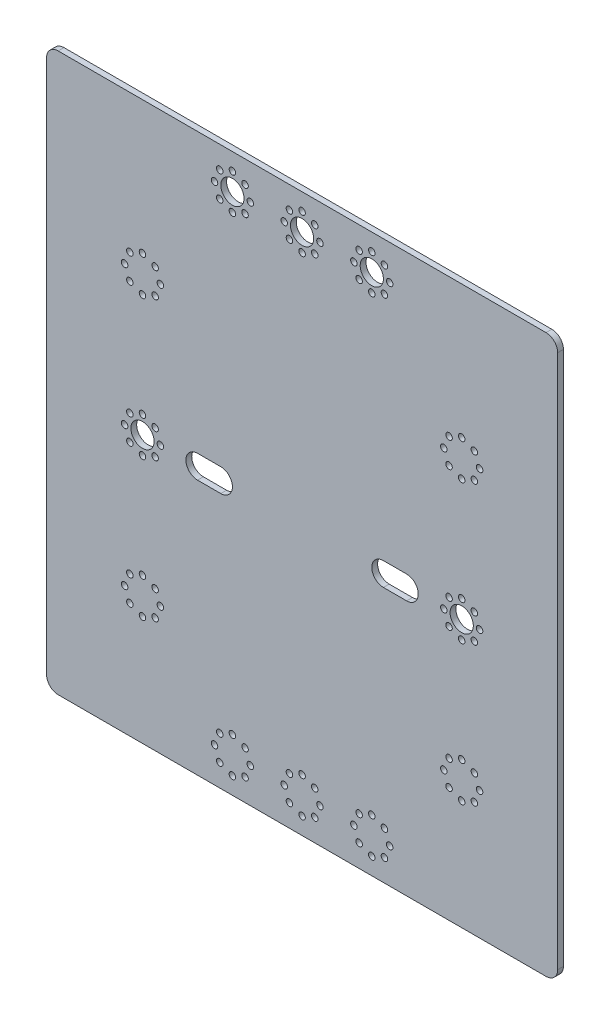
from build123d import *

# Parameters (mm, degrees)
SKETCH1_W                  = 279.4
SKETCH1_H                  = 304.8
BOSS_EXTRUDE1_DEPTH        = 3.175
SKETCH2_R                  = 6.35
CUT_EXTRUDE1_DEPTH         = 3.175
SKETCH3_R                  = 1.778
CUT_EXTRUDE2_DEPTH         = 3.175
CIRPATTERN1_COUNT          = 8
SKETCH4_R                  = 1.778
CUT_EXTRUDE3_DEPTH         = 3.175
CIRPATTERN2_COUNT          = 8
MIRROR1_COPY_1_SKETCH_R    = 1.778
MIRROR1_COPY_1_DEPTH       = 3.175
MIRROR1_COPY_2_SKETCH_R    = 1.778
MIRROR1_COPY_2_DEPTH       = 3.175
MIRROR1_COPY_3_SKETCH_R    = 1.778
MIRROR1_COPY_3_DEPTH       = 3.175
MIRROR1_COPY_4_SKETCH_R    = 1.778
MIRROR1_COPY_4_DEPTH       = 3.175
MIRROR1_COPY_5_SKETCH_R    = 1.778
MIRROR1_COPY_5_DEPTH       = 3.175
MIRROR1_COPY_6_SKETCH_R    = 1.778
MIRROR1_COPY_6_DEPTH       = 3.175
MIRROR1_COPY_7_SKETCH_R    = 1.778
MIRROR1_COPY_7_DEPTH       = 3.175
LPATTERN2_COUNT            = 4
LPATTERN2_PITCH            = 38.1
LPATTERN2_COPY_1_SKETCH_R  = 6.35
LPATTERN2_COPY_1_DEPTH     = 3.175
LPATTERN2_COPY_2_SKETCH_R  = 1.778
LPATTERN2_COPY_2_DEPTH     = 3.175
LPATTERN2_COPY_3_SKETCH_R  = 1.778
LPATTERN2_COPY_3_DEPTH     = 3.175
LPATTERN2_COPY_4_SKETCH_R  = 1.778
LPATTERN2_COPY_4_DEPTH     = 3.175
LPATTERN2_COPY_5_SKETCH_R  = 1.778
LPATTERN2_COPY_5_DEPTH     = 3.175
LPATTERN2_COPY_6_SKETCH_R  = 1.778
LPATTERN2_COPY_6_DEPTH     = 3.175
LPATTERN2_COPY_7_SKETCH_R  = 1.778
LPATTERN2_COPY_7_DEPTH     = 3.175
LPATTERN2_COPY_8_SKETCH_R  = 1.778
LPATTERN2_COPY_8_DEPTH     = 3.175
LPATTERN2_COPY_9_SKETCH_R  = 1.778
LPATTERN2_COPY_9_DEPTH     = 3.175
LPATTERN2_COPY_10_SKETCH_R = 1.778
LPATTERN2_COPY_10_DEPTH    = 3.175
LPATTERN2_COPY_11_SKETCH_R = 1.778
LPATTERN2_COPY_11_DEPTH    = 3.175
LPATTERN2_COPY_12_SKETCH_R = 1.778
LPATTERN2_COPY_12_DEPTH    = 3.175
LPATTERN2_COPY_13_SKETCH_R = 1.778
LPATTERN2_COPY_13_DEPTH    = 3.175
LPATTERN2_COPY_14_SKETCH_R = 1.778
LPATTERN2_COPY_14_DEPTH    = 3.175
LPATTERN2_COPY_15_SKETCH_R = 1.778
LPATTERN2_COPY_15_DEPTH    = 3.175
LPATTERN2_COPY_16_SKETCH_R = 1.778
LPATTERN2_COPY_16_DEPTH    = 3.175
LPATTERN3_COUNT            = 4
LPATTERN3_PITCH            = 38.1
LPATTERN3_COPY_1_SKETCH_R  = 1.778
LPATTERN3_COPY_1_DEPTH     = 3.175
LPATTERN3_COPY_2_SKETCH_R  = 1.778
LPATTERN3_COPY_2_DEPTH     = 3.175
LPATTERN3_COPY_3_SKETCH_R  = 1.778
LPATTERN3_COPY_3_DEPTH     = 3.175
LPATTERN3_COPY_4_SKETCH_R  = 1.778
LPATTERN3_COPY_4_DEPTH     = 3.175
LPATTERN3_COPY_5_SKETCH_R  = 1.778
LPATTERN3_COPY_5_DEPTH     = 3.175
LPATTERN3_COPY_6_SKETCH_R  = 1.778
LPATTERN3_COPY_6_DEPTH     = 3.175
LPATTERN3_COPY_7_SKETCH_R  = 1.778
LPATTERN3_COPY_7_DEPTH     = 3.175
SKETCH5_R                  = 6.35
BOSS_EXTRUDE4_DEPTH        = 3.175
MIRROR4_COPY_1_SKETCH_R    = 1.778
MIRROR4_COPY_1_DEPTH       = 3.175
MIRROR4_COPY_2_SKETCH_R    = 1.778
MIRROR4_COPY_2_DEPTH       = 3.175
MIRROR4_COPY_3_SKETCH_R    = 1.778
MIRROR4_COPY_3_DEPTH       = 3.175
MIRROR4_COPY_4_SKETCH_R    = 1.778
MIRROR4_COPY_4_DEPTH       = 3.175
MIRROR4_COPY_5_SKETCH_R    = 1.778
MIRROR4_COPY_5_DEPTH       = 3.175
MIRROR4_COPY_6_SKETCH_R    = 1.778
MIRROR4_COPY_6_DEPTH       = 3.175
MIRROR4_COPY_7_SKETCH_R    = 1.778
MIRROR4_COPY_7_DEPTH       = 3.175
MIRROR4_COPY_8_SKETCH_R    = 1.778
MIRROR4_COPY_8_DEPTH       = 3.175
MIRROR4_COPY_9_SKETCH_R    = 1.778
MIRROR4_COPY_9_DEPTH       = 3.175
SKETCH6_R                  = 6.35
CUT_EXTRUDE4_DEPTH         = 3.175
SKETCH7_R                  = 1.778
CUT_EXTRUDE5_DEPTH         = 3.175
CIRPATTERN3_COUNT          = 8
SKETCH8_R                  = 1.778
CUT_EXTRUDE6_DEPTH         = 3.175
CIRPATTERN4_COUNT          = 8
MIRROR5_COPY_1_SKETCH_R    = 1.778
MIRROR5_COPY_1_DEPTH       = 3.175
MIRROR5_COPY_2_SKETCH_R    = 1.778
MIRROR5_COPY_2_DEPTH       = 3.175
MIRROR5_COPY_3_SKETCH_R    = 1.778
MIRROR5_COPY_3_DEPTH       = 3.175
MIRROR5_COPY_4_SKETCH_R    = 1.778
MIRROR5_COPY_4_DEPTH       = 3.175
MIRROR5_COPY_5_SKETCH_R    = 1.778
MIRROR5_COPY_5_DEPTH       = 3.175
MIRROR5_COPY_6_SKETCH_R    = 1.778
MIRROR5_COPY_6_DEPTH       = 3.175
MIRROR5_COPY_7_SKETCH_R    = 1.778
MIRROR5_COPY_7_DEPTH       = 3.175
MIRROR5_COPY_8_SKETCH_R    = 1.778
MIRROR5_COPY_8_DEPTH       = 3.175
MIRROR5_COPY_9_SKETCH_R    = 1.778
MIRROR5_COPY_9_DEPTH       = 3.175
MIRROR5_COPY_10_SKETCH_R   = 1.778
MIRROR5_COPY_10_DEPTH      = 3.175
MIRROR5_COPY_11_SKETCH_R   = 1.778
MIRROR5_COPY_11_DEPTH      = 3.175
MIRROR5_COPY_12_SKETCH_R   = 1.778
MIRROR5_COPY_12_DEPTH      = 3.175
MIRROR5_COPY_13_SKETCH_R   = 1.778
MIRROR5_COPY_13_DEPTH      = 3.175
MIRROR5_COPY_14_SKETCH_R   = 1.778
MIRROR5_COPY_14_DEPTH      = 3.175
FILLET1_R                  = 6.35
CUT_EXTRUDE8_DEPTH         = 3.175
MIRROR8_COPY_1_SKETCH_R    = 1.778
MIRROR8_COPY_1_DEPTH       = 3.175
MIRROR8_COPY_2_SKETCH_R    = 1.778
MIRROR8_COPY_2_DEPTH       = 3.175
MIRROR8_COPY_3_SKETCH_R    = 1.778
MIRROR8_COPY_3_DEPTH       = 3.175
MIRROR8_COPY_4_SKETCH_R    = 1.778
MIRROR8_COPY_4_DEPTH       = 3.175
MIRROR8_COPY_5_SKETCH_R    = 1.778
MIRROR8_COPY_5_DEPTH       = 3.175
MIRROR8_COPY_6_SKETCH_R    = 1.778
MIRROR8_COPY_6_DEPTH       = 3.175
MIRROR8_COPY_7_SKETCH_R    = 1.778
MIRROR8_COPY_7_DEPTH       = 3.175


with BuildPart() as part:
    # Sketch1 → Boss-Extrude1 (new body)
    with BuildSketch(Plane.XY):
        with Locations((-139.7, -152.4)):
            Rectangle(SKETCH1_W, SKETCH1_H)
    extrude(amount=BOSS_EXTRUDE1_DEPTH)

    # Sketch2 → Cut-Extrude1 (cut)
    with BuildSketch(Plane.XY.offset(3.175)):
        with Locations((-139.7, -19.05)):
            Circle(SKETCH2_R)
        with Locations((-226.949, -158.75)):
            Circle(SKETCH2_R)
    cut_extrude1 = extrude(amount=-CUT_EXTRUDE1_DEPTH, mode=Mode.SUBTRACT)

    # Sketch3 → Cut-Extrude2 (cut)
    with BuildSketch(Plane.XY.offset(3.175)):
        with Locations((-139.7, -9.271)):
            Circle(SKETCH3_R)
    cut_extrude2 = extrude(amount=-CUT_EXTRUDE2_DEPTH, mode=Mode.SUBTRACT)

    # CirPattern1: Cut-Extrude2 ×8 about axis
    cirpattern1_axis = Axis((-139.7, -19.05, 0), (0, 0, 1))
    for i in range(1, CIRPATTERN1_COUNT):
        add(cut_extrude2.rotate(cirpattern1_axis, i * 360 / CIRPATTERN1_COUNT), mode=Mode.SUBTRACT)

    # Sketch4 → Cut-Extrude3 (cut)
    with BuildSketch(Plane.XY.offset(3.175)):
        with Locations((-226.949, -148.971)):
            Circle(SKETCH4_R)
    cut_extrude3 = extrude(amount=-CUT_EXTRUDE3_DEPTH, mode=Mode.SUBTRACT)

    # CirPattern2: Cut-Extrude3 ×8 about axis
    cirpattern2_axis = Axis((-226.949, -158.75, 0), (0, 0, 1))
    for i in range(1, CIRPATTERN2_COUNT):
        add(cut_extrude3.rotate(cirpattern2_axis, i * 360 / CIRPATTERN2_COUNT), mode=Mode.SUBTRACT)

    # Mirror1: Cut-Extrude1, Cut-Extrude3 across plane
    add(cut_extrude1.mirror(Plane.ZY.offset(139.7)), mode=Mode.SUBTRACT)
    add(cut_extrude3.mirror(Plane.ZY.offset(139.7)), mode=Mode.SUBTRACT)

    # Mirror1 copy 1 sketch → Mirror1 copy 1 (cut)
    with BuildSketch(Plane(origin=(-100.67497537, 113.980378397, 3.175), x_dir=(-0.707106781, 0.707106781, 0), z_dir=(0, 0, 1))):
        with Locations((-226.949, 148.971)):
            Circle(MIRROR1_COPY_1_SKETCH_R)
    extrude(amount=-MIRROR1_COPY_1_DEPTH, mode=Mode.SUBTRACT)

    # Mirror1 copy 2 sketch → Mirror1 copy 2 (cut)
    with BuildSketch(Plane(origin=(106.299, 68.199, 3.175), x_dir=(0, 1, 0), z_dir=(0, 0, 1))):
        with Locations((-226.949, 148.971)):
            Circle(MIRROR1_COPY_2_SKETCH_R)
    extrude(amount=-MIRROR1_COPY_2_DEPTH, mode=Mode.SUBTRACT)

    # Mirror1 copy 3 sketch → Mirror1 copy 3 (cut)
    with BuildSketch(Plane(origin=(220.279378397, -110.52602463, 3.175), x_dir=(0.707106781, 0.707106781, 0), z_dir=(0, 0, 1))):
        with Locations((-226.949, 148.971)):
            Circle(MIRROR1_COPY_3_SKETCH_R)
    extrude(amount=-MIRROR1_COPY_3_DEPTH, mode=Mode.SUBTRACT)

    # Mirror1 copy 4 sketch → Mirror1 copy 4 (cut)
    with BuildSketch(Plane(origin=(174.498, -317.5, 3.175), x_dir=(1, 0, 0), z_dir=(0, 0, 1))):
        with Locations((-226.949, 148.971)):
            Circle(MIRROR1_COPY_4_SKETCH_R)
    extrude(amount=-MIRROR1_COPY_4_DEPTH, mode=Mode.SUBTRACT)

    # Mirror1 copy 5 sketch → Mirror1 copy 5 (cut)
    with BuildSketch(Plane(origin=(-4.22702463, -431.480378397, 3.175), x_dir=(0.707106781, -0.707106781, 0), z_dir=(0, 0, 1))):
        with Locations((-226.949, 148.971)):
            Circle(MIRROR1_COPY_5_SKETCH_R)
    extrude(amount=-MIRROR1_COPY_5_DEPTH, mode=Mode.SUBTRACT)

    # Mirror1 copy 6 sketch → Mirror1 copy 6 (cut)
    with BuildSketch(Plane(origin=(-211.201, -385.699, 3.175), x_dir=(0, -1, 0), z_dir=(0, 0, 1))):
        with Locations((-226.949, 148.971)):
            Circle(MIRROR1_COPY_6_SKETCH_R)
    extrude(amount=-MIRROR1_COPY_6_DEPTH, mode=Mode.SUBTRACT)

    # Mirror1 copy 7 sketch → Mirror1 copy 7 (cut)
    with BuildSketch(Plane(origin=(-325.181378397, -206.97397537, 3.175), x_dir=(-0.707106781, -0.707106781, 0), z_dir=(0, 0, 1))):
        with Locations((-226.949, 148.971)):
            Circle(MIRROR1_COPY_7_SKETCH_R)
    extrude(amount=-MIRROR1_COPY_7_DEPTH, mode=Mode.SUBTRACT)

    # LPattern2: Cut-Extrude1, Cut-Extrude3 ×4, 2 skipped
    with Locations(*[(0, i * LPATTERN2_PITCH, 0) for i in range(1, LPATTERN2_COUNT) if i not in (1, 3)]):
        add(cut_extrude1, mode=Mode.SUBTRACT)
        add(cut_extrude3, mode=Mode.SUBTRACT)

    # LPattern2 copy 1 sketch → LPattern2 copy 1 (cut)
    with BuildSketch(Plane(origin=(-279.4, 76.2, 3.175), x_dir=(-1, 0, 0), z_dir=(0, 0, 1))):
        with Locations((-139.7, 19.05)):
            Circle(LPATTERN2_COPY_1_SKETCH_R)
        with Locations((-226.949, 158.75)):
            Circle(LPATTERN2_COPY_1_SKETCH_R)
    extrude(amount=-LPATTERN2_COPY_1_DEPTH, mode=Mode.SUBTRACT)

    # LPattern2 copy 2 sketch → LPattern2 copy 2 (cut)
    with BuildSketch(Plane(origin=(-279.4, 76.2, 3.175), x_dir=(-1, 0, 0), z_dir=(0, 0, 1))):
        with Locations((-226.949, 148.971)):
            Circle(LPATTERN2_COPY_2_SKETCH_R)
    extrude(amount=-LPATTERN2_COPY_2_DEPTH, mode=Mode.SUBTRACT)

    # LPattern2 copy 3 sketch → LPattern2 copy 3 (cut)
    with BuildSketch(Plane(origin=(-100.67497537, 190.180378397, 3.175), x_dir=(-0.707106781, 0.707106781, 0), z_dir=(0, 0, 1))):
        with Locations((-226.949, 148.971)):
            Circle(LPATTERN2_COPY_3_SKETCH_R)
    extrude(amount=-LPATTERN2_COPY_3_DEPTH, mode=Mode.SUBTRACT)

    # LPattern2 copy 4 sketch → LPattern2 copy 4 (cut)
    with BuildSketch(Plane(origin=(106.299, 144.399, 3.175), x_dir=(0, 1, 0), z_dir=(0, 0, 1))):
        with Locations((-226.949, 148.971)):
            Circle(LPATTERN2_COPY_4_SKETCH_R)
    extrude(amount=-LPATTERN2_COPY_4_DEPTH, mode=Mode.SUBTRACT)

    # LPattern2 copy 5 sketch → LPattern2 copy 5 (cut)
    with BuildSketch(Plane(origin=(220.279378397, -34.32602463, 3.175), x_dir=(0.707106781, 0.707106781, 0), z_dir=(0, 0, 1))):
        with Locations((-226.949, 148.971)):
            Circle(LPATTERN2_COPY_5_SKETCH_R)
    extrude(amount=-LPATTERN2_COPY_5_DEPTH, mode=Mode.SUBTRACT)

    # LPattern2 copy 6 sketch → LPattern2 copy 6 (cut)
    with BuildSketch(Plane(origin=(174.498, -241.3, 3.175), x_dir=(1, 0, 0), z_dir=(0, 0, 1))):
        with Locations((-226.949, 148.971)):
            Circle(LPATTERN2_COPY_6_SKETCH_R)
    extrude(amount=-LPATTERN2_COPY_6_DEPTH, mode=Mode.SUBTRACT)

    # LPattern2 copy 7 sketch → LPattern2 copy 7 (cut)
    with BuildSketch(Plane(origin=(-4.22702463, -355.280378397, 3.175), x_dir=(0.707106781, -0.707106781, 0), z_dir=(0, 0, 1))):
        with Locations((-226.949, 148.971)):
            Circle(LPATTERN2_COPY_7_SKETCH_R)
    extrude(amount=-LPATTERN2_COPY_7_DEPTH, mode=Mode.SUBTRACT)

    # LPattern2 copy 8 sketch → LPattern2 copy 8 (cut)
    with BuildSketch(Plane(origin=(-211.201, -309.499, 3.175), x_dir=(0, -1, 0), z_dir=(0, 0, 1))):
        with Locations((-226.949, 148.971)):
            Circle(LPATTERN2_COPY_8_SKETCH_R)
    extrude(amount=-LPATTERN2_COPY_8_DEPTH, mode=Mode.SUBTRACT)

    # LPattern2 copy 9 sketch → LPattern2 copy 9 (cut)
    with BuildSketch(Plane(origin=(-325.181378397, -130.77397537, 3.175), x_dir=(-0.707106781, -0.707106781, 0), z_dir=(0, 0, 1))):
        with Locations((-226.949, 148.971)):
            Circle(LPATTERN2_COPY_9_SKETCH_R)
    extrude(amount=-LPATTERN2_COPY_9_DEPTH, mode=Mode.SUBTRACT)

    # LPattern2 copy 10 sketch → LPattern2 copy 10 (cut)
    with BuildSketch(Plane(origin=(-178.72502463, 190.180378397, 3.175), x_dir=(0.707106781, 0.707106781, 0), z_dir=(0, 0, 1))):
        with Locations((-226.949, -148.971)):
            Circle(LPATTERN2_COPY_10_SKETCH_R)
    extrude(amount=-LPATTERN2_COPY_10_DEPTH, mode=Mode.SUBTRACT)

    # LPattern2 copy 11 sketch → LPattern2 copy 11 (cut)
    with BuildSketch(Plane(origin=(-385.699, 144.399, 3.175), x_dir=(0, 1, 0), z_dir=(0, 0, 1))):
        with Locations((-226.949, -148.971)):
            Circle(LPATTERN2_COPY_11_SKETCH_R)
    extrude(amount=-LPATTERN2_COPY_11_DEPTH, mode=Mode.SUBTRACT)

    # LPattern2 copy 12 sketch → LPattern2 copy 12 (cut)
    with BuildSketch(Plane(origin=(-499.679378397, -34.32602463, 3.175), x_dir=(-0.707106781, 0.707106781, 0), z_dir=(0, 0, 1))):
        with Locations((-226.949, -148.971)):
            Circle(LPATTERN2_COPY_12_SKETCH_R)
    extrude(amount=-LPATTERN2_COPY_12_DEPTH, mode=Mode.SUBTRACT)

    # LPattern2 copy 13 sketch → LPattern2 copy 13 (cut)
    with BuildSketch(Plane(origin=(-453.898, -241.3, 3.175), x_dir=(-1, 0, 0), z_dir=(0, 0, 1))):
        with Locations((-226.949, -148.971)):
            Circle(LPATTERN2_COPY_13_SKETCH_R)
    extrude(amount=-LPATTERN2_COPY_13_DEPTH, mode=Mode.SUBTRACT)

    # LPattern2 copy 14 sketch → LPattern2 copy 14 (cut)
    with BuildSketch(Plane(origin=(-275.17297537, -355.280378397, 3.175), x_dir=(-0.707106781, -0.707106781, 0), z_dir=(0, 0, 1))):
        with Locations((-226.949, -148.971)):
            Circle(LPATTERN2_COPY_14_SKETCH_R)
    extrude(amount=-LPATTERN2_COPY_14_DEPTH, mode=Mode.SUBTRACT)

    # LPattern2 copy 15 sketch → LPattern2 copy 15 (cut)
    with BuildSketch(Plane(origin=(-68.199, -309.499, 3.175), x_dir=(0, -1, 0), z_dir=(0, 0, 1))):
        with Locations((-226.949, -148.971)):
            Circle(LPATTERN2_COPY_15_SKETCH_R)
    extrude(amount=-LPATTERN2_COPY_15_DEPTH, mode=Mode.SUBTRACT)

    # LPattern2 copy 16 sketch → LPattern2 copy 16 (cut)
    with BuildSketch(Plane(origin=(45.781378397, -130.77397537, 3.175), x_dir=(0.707106781, -0.707106781, 0), z_dir=(0, 0, 1))):
        with Locations((-226.949, -148.971)):
            Circle(LPATTERN2_COPY_16_SKETCH_R)
    extrude(amount=-LPATTERN2_COPY_16_DEPTH, mode=Mode.SUBTRACT)

    # LPattern3: Cut-Extrude3 ×4, 2 skipped
    with Locations(*[(0, -i * LPATTERN3_PITCH, 0) for i in range(1, LPATTERN3_COUNT) if i not in (1, 3)]):
        add(cut_extrude3, mode=Mode.SUBTRACT)

    # LPattern3 copy 1 sketch → LPattern3 copy 1 (cut)
    with BuildSketch(Plane(origin=(-178.72502463, 37.780378397, 3.175), x_dir=(0.707106781, 0.707106781, 0), z_dir=(0, 0, 1))):
        with Locations((-226.949, -148.971)):
            Circle(LPATTERN3_COPY_1_SKETCH_R)
    extrude(amount=-LPATTERN3_COPY_1_DEPTH, mode=Mode.SUBTRACT)

    # LPattern3 copy 2 sketch → LPattern3 copy 2 (cut)
    with BuildSketch(Plane(origin=(-385.699, -8.001, 3.175), x_dir=(0, 1, 0), z_dir=(0, 0, 1))):
        with Locations((-226.949, -148.971)):
            Circle(LPATTERN3_COPY_2_SKETCH_R)
    extrude(amount=-LPATTERN3_COPY_2_DEPTH, mode=Mode.SUBTRACT)

    # LPattern3 copy 3 sketch → LPattern3 copy 3 (cut)
    with BuildSketch(Plane(origin=(-499.679378397, -186.72602463, 3.175), x_dir=(-0.707106781, 0.707106781, 0), z_dir=(0, 0, 1))):
        with Locations((-226.949, -148.971)):
            Circle(LPATTERN3_COPY_3_SKETCH_R)
    extrude(amount=-LPATTERN3_COPY_3_DEPTH, mode=Mode.SUBTRACT)

    # LPattern3 copy 4 sketch → LPattern3 copy 4 (cut)
    with BuildSketch(Plane(origin=(-453.898, -393.7, 3.175), x_dir=(-1, 0, 0), z_dir=(0, 0, 1))):
        with Locations((-226.949, -148.971)):
            Circle(LPATTERN3_COPY_4_SKETCH_R)
    extrude(amount=-LPATTERN3_COPY_4_DEPTH, mode=Mode.SUBTRACT)

    # LPattern3 copy 5 sketch → LPattern3 copy 5 (cut)
    with BuildSketch(Plane(origin=(-275.17297537, -507.680378397, 3.175), x_dir=(-0.707106781, -0.707106781, 0), z_dir=(0, 0, 1))):
        with Locations((-226.949, -148.971)):
            Circle(LPATTERN3_COPY_5_SKETCH_R)
    extrude(amount=-LPATTERN3_COPY_5_DEPTH, mode=Mode.SUBTRACT)

    # LPattern3 copy 6 sketch → LPattern3 copy 6 (cut)
    with BuildSketch(Plane(origin=(-68.199, -461.899, 3.175), x_dir=(0, -1, 0), z_dir=(0, 0, 1))):
        with Locations((-226.949, -148.971)):
            Circle(LPATTERN3_COPY_6_SKETCH_R)
    extrude(amount=-LPATTERN3_COPY_6_DEPTH, mode=Mode.SUBTRACT)

    # LPattern3 copy 7 sketch → LPattern3 copy 7 (cut)
    with BuildSketch(Plane(origin=(45.781378397, -283.17397537, 3.175), x_dir=(0.707106781, -0.707106781, 0), z_dir=(0, 0, 1))):
        with Locations((-226.949, -148.971)):
            Circle(LPATTERN3_COPY_7_SKETCH_R)
    extrude(amount=-LPATTERN3_COPY_7_DEPTH, mode=Mode.SUBTRACT)

    # Sketch5 → Boss-Extrude4 (add)
    with BuildSketch(Plane.XY.offset(3.175)):
        with Locations((-226.949, -82.55)):
            Circle(SKETCH5_R)
        with Locations((-52.451, -82.55)):
            Circle(SKETCH5_R)
    extrude(amount=-BOSS_EXTRUDE4_DEPTH)

    # Mirror4 copy 1 sketch → Mirror4 copy 1 (cut)
    with BuildSketch(Plane(origin=(-279.4, -76.2, 3.175), x_dir=(-1, 0, 0), z_dir=(0, 0, 1))):
        with Locations((-226.949, 148.971)):
            Circle(MIRROR4_COPY_1_SKETCH_R)
    extrude(amount=-MIRROR4_COPY_1_DEPTH, mode=Mode.SUBTRACT)

    # Mirror4 copy 2 sketch → Mirror4 copy 2 (cut)
    with BuildSketch(Plane(origin=(-100.67497537, 37.780378397, 3.175), x_dir=(-0.707106781, 0.707106781, 0), z_dir=(0, 0, 1))):
        with Locations((-226.949, 148.971)):
            Circle(MIRROR4_COPY_2_SKETCH_R)
    extrude(amount=-MIRROR4_COPY_2_DEPTH, mode=Mode.SUBTRACT)

    # Mirror4 copy 3 sketch → Mirror4 copy 3 (cut)
    with BuildSketch(Plane(origin=(106.299, -8.001, 3.175), x_dir=(0, 1, 0), z_dir=(0, 0, 1))):
        with Locations((-226.949, 148.971)):
            Circle(MIRROR4_COPY_3_SKETCH_R)
    extrude(amount=-MIRROR4_COPY_3_DEPTH, mode=Mode.SUBTRACT)

    # Mirror4 copy 4 sketch → Mirror4 copy 4 (cut)
    with BuildSketch(Plane(origin=(220.279378397, -186.72602463, 3.175), x_dir=(0.707106781, 0.707106781, 0), z_dir=(0, 0, 1))):
        with Locations((-226.949, 148.971)):
            Circle(MIRROR4_COPY_4_SKETCH_R)
    extrude(amount=-MIRROR4_COPY_4_DEPTH, mode=Mode.SUBTRACT)

    # Mirror4 copy 5 sketch → Mirror4 copy 5 (cut)
    with BuildSketch(Plane(origin=(174.498, -393.7, 3.175), x_dir=(1, 0, 0), z_dir=(0, 0, 1))):
        with Locations((-226.949, 148.971)):
            Circle(MIRROR4_COPY_5_SKETCH_R)
    extrude(amount=-MIRROR4_COPY_5_DEPTH, mode=Mode.SUBTRACT)

    # Mirror4 copy 6 sketch → Mirror4 copy 6 (cut)
    with BuildSketch(Plane(origin=(-4.22702463, -507.680378397, 3.175), x_dir=(0.707106781, -0.707106781, 0), z_dir=(0, 0, 1))):
        with Locations((-226.949, 148.971)):
            Circle(MIRROR4_COPY_6_SKETCH_R)
    extrude(amount=-MIRROR4_COPY_6_DEPTH, mode=Mode.SUBTRACT)

    # Mirror4 copy 7 sketch → Mirror4 copy 7 (cut)
    with BuildSketch(Plane(origin=(-211.201, -461.899, 3.175), x_dir=(0, -1, 0), z_dir=(0, 0, 1))):
        with Locations((-226.949, 148.971)):
            Circle(MIRROR4_COPY_7_SKETCH_R)
    extrude(amount=-MIRROR4_COPY_7_DEPTH, mode=Mode.SUBTRACT)

    # Mirror4 copy 8 sketch → Mirror4 copy 8 (cut)
    with BuildSketch(Plane(origin=(-325.181378397, -283.17397537, 3.175), x_dir=(-0.707106781, -0.707106781, 0), z_dir=(0, 0, 1))):
        with Locations((-226.949, 148.971)):
            Circle(MIRROR4_COPY_8_SKETCH_R)
    extrude(amount=-MIRROR4_COPY_8_DEPTH, mode=Mode.SUBTRACT)

    # Mirror4 copy 9 sketch → Mirror4 copy 9 (cut)
    with BuildSketch(Plane(origin=(-279.4, 0, 3.175), x_dir=(-1, 0, 0), z_dir=(0, 0, 1))):
        with Locations((-226.949, 148.971)):
            Circle(MIRROR4_COPY_9_SKETCH_R)
    extrude(amount=-MIRROR4_COPY_9_DEPTH, mode=Mode.SUBTRACT)

    # Sketch6 → Cut-Extrude4 (cut)
    with BuildSketch(Plane.XY.offset(3.175)):
        with Locations((-101.6, -19.05)):
            Circle(SKETCH6_R)
        with Locations((-177.8, -19.05)):
            Circle(SKETCH6_R)
    extrude(amount=-CUT_EXTRUDE4_DEPTH, mode=Mode.SUBTRACT)

    # Sketch7 → Cut-Extrude5 (cut)
    with BuildSketch(Plane.XY.offset(3.175)):
        with Locations((-177.8, -9.271)):
            Circle(SKETCH7_R)
    cut_extrude5 = extrude(amount=-CUT_EXTRUDE5_DEPTH, mode=Mode.SUBTRACT)

    # CirPattern3: Cut-Extrude5 ×8 about axis
    cirpattern3_axis = Axis((-177.8, -19.05, 0), (0, 0, 1))
    for i in range(1, CIRPATTERN3_COUNT):
        add(cut_extrude5.rotate(cirpattern3_axis, i * 360 / CIRPATTERN3_COUNT), mode=Mode.SUBTRACT)

    # Sketch8 → Cut-Extrude6 (cut)
    with BuildSketch(Plane.XY.offset(3.175)):
        with Locations((-101.6, -9.271)):
            Circle(SKETCH8_R)
    cut_extrude6 = extrude(amount=-CUT_EXTRUDE6_DEPTH, mode=Mode.SUBTRACT)

    # CirPattern4: Cut-Extrude6 ×8 about axis
    cirpattern4_axis = Axis((-101.6, -19.05, 0), (0, 0, 1))
    for i in range(1, CIRPATTERN4_COUNT):
        add(cut_extrude6.rotate(cirpattern4_axis, i * 360 / CIRPATTERN4_COUNT), mode=Mode.SUBTRACT)

    # Mirror5: Cut-Extrude5, Cut-Extrude6 across plane
    add(cut_extrude5.mirror(Plane.ZX.offset(-152.4)), mode=Mode.SUBTRACT)
    add(cut_extrude6.mirror(Plane.ZX.offset(-152.4)), mode=Mode.SUBTRACT)

    # Mirror5 copy 1 sketch → Mirror5 copy 1 (cut)
    with BuildSketch(Plane(origin=(-65.546798487, -424.943969877, 3.175), x_dir=(0.707106781, -0.707106781, 0), z_dir=(0, 0, 1))):
        with Locations((-177.8, 9.271)):
            Circle(MIRROR5_COPY_1_SKETCH_R)
    extrude(amount=-MIRROR5_COPY_1_DEPTH, mode=Mode.SUBTRACT)

    # Mirror5 copy 2 sketch → Mirror5 copy 2 (cut)
    with BuildSketch(Plane(origin=(-196.85, -463.55, 3.175), x_dir=(0, -1, 0), z_dir=(0, 0, 1))):
        with Locations((-177.8, 9.271)):
            Circle(MIRROR5_COPY_2_SKETCH_R)
    extrude(amount=-MIRROR5_COPY_2_DEPTH, mode=Mode.SUBTRACT)

    # Mirror5 copy 3 sketch → Mirror5 copy 3 (cut)
    with BuildSketch(Plane(origin=(-316.993969877, -398.003201513, 3.175), x_dir=(-0.707106781, -0.707106781, 0), z_dir=(0, 0, 1))):
        with Locations((-177.8, 9.271)):
            Circle(MIRROR5_COPY_3_SKETCH_R)
    extrude(amount=-MIRROR5_COPY_3_DEPTH, mode=Mode.SUBTRACT)

    # Mirror5 copy 4 sketch → Mirror5 copy 4 (cut)
    with BuildSketch(Plane(origin=(-355.6, -266.7, 3.175), x_dir=(-1, 0, 0), z_dir=(0, 0, 1))):
        with Locations((-177.8, 9.271)):
            Circle(MIRROR5_COPY_4_SKETCH_R)
    extrude(amount=-MIRROR5_COPY_4_DEPTH, mode=Mode.SUBTRACT)

    # Mirror5 copy 5 sketch → Mirror5 copy 5 (cut)
    with BuildSketch(Plane(origin=(-290.053201513, -146.556030123, 3.175), x_dir=(-0.707106781, 0.707106781, 0), z_dir=(0, 0, 1))):
        with Locations((-177.8, 9.271)):
            Circle(MIRROR5_COPY_5_SKETCH_R)
    extrude(amount=-MIRROR5_COPY_5_DEPTH, mode=Mode.SUBTRACT)

    # Mirror5 copy 6 sketch → Mirror5 copy 6 (cut)
    with BuildSketch(Plane(origin=(-158.75, -107.95, 3.175), x_dir=(0, 1, 0), z_dir=(0, 0, 1))):
        with Locations((-177.8, 9.271)):
            Circle(MIRROR5_COPY_6_SKETCH_R)
    extrude(amount=-MIRROR5_COPY_6_DEPTH, mode=Mode.SUBTRACT)

    # Mirror5 copy 7 sketch → Mirror5 copy 7 (cut)
    with BuildSketch(Plane(origin=(-38.606030123, -173.496798487, 3.175), x_dir=(0.707106781, 0.707106781, 0), z_dir=(0, 0, 1))):
        with Locations((-177.8, 9.271)):
            Circle(MIRROR5_COPY_7_SKETCH_R)
    extrude(amount=-MIRROR5_COPY_7_DEPTH, mode=Mode.SUBTRACT)

    # Mirror5 copy 8 sketch → Mirror5 copy 8 (cut)
    with BuildSketch(Plane(origin=(-43.228335213, -371.06243315, 3.175), x_dir=(0.707106781, -0.707106781, 0), z_dir=(0, 0, 1))):
        with Locations((-101.6, 9.271)):
            Circle(MIRROR5_COPY_8_SKETCH_R)
    extrude(amount=-MIRROR5_COPY_8_DEPTH, mode=Mode.SUBTRACT)

    # Mirror5 copy 9 sketch → Mirror5 copy 9 (cut)
    with BuildSketch(Plane(origin=(-120.65, -387.35, 3.175), x_dir=(0, -1, 0), z_dir=(0, 0, 1))):
        with Locations((-101.6, 9.271)):
            Circle(MIRROR5_COPY_9_SKETCH_R)
    extrude(amount=-MIRROR5_COPY_9_DEPTH, mode=Mode.SUBTRACT)

    # Mirror5 copy 10 sketch → Mirror5 copy 10 (cut)
    with BuildSketch(Plane(origin=(-186.91243315, -344.121664787, 3.175), x_dir=(-0.707106781, -0.707106781, 0), z_dir=(0, 0, 1))):
        with Locations((-101.6, 9.271)):
            Circle(MIRROR5_COPY_10_SKETCH_R)
    extrude(amount=-MIRROR5_COPY_10_DEPTH, mode=Mode.SUBTRACT)

    # Mirror5 copy 11 sketch → Mirror5 copy 11 (cut)
    with BuildSketch(Plane(origin=(-203.2, -266.7, 3.175), x_dir=(-1, 0, 0), z_dir=(0, 0, 1))):
        with Locations((-101.6, 9.271)):
            Circle(MIRROR5_COPY_11_SKETCH_R)
    extrude(amount=-MIRROR5_COPY_11_DEPTH, mode=Mode.SUBTRACT)

    # Mirror5 copy 12 sketch → Mirror5 copy 12 (cut)
    with BuildSketch(Plane(origin=(-159.971664787, -200.43756685, 3.175), x_dir=(-0.707106781, 0.707106781, 0), z_dir=(0, 0, 1))):
        with Locations((-101.6, 9.271)):
            Circle(MIRROR5_COPY_12_SKETCH_R)
    extrude(amount=-MIRROR5_COPY_12_DEPTH, mode=Mode.SUBTRACT)

    # Mirror5 copy 13 sketch → Mirror5 copy 13 (cut)
    with BuildSketch(Plane(origin=(-82.55, -184.15, 3.175), x_dir=(0, 1, 0), z_dir=(0, 0, 1))):
        with Locations((-101.6, 9.271)):
            Circle(MIRROR5_COPY_13_SKETCH_R)
    extrude(amount=-MIRROR5_COPY_13_DEPTH, mode=Mode.SUBTRACT)

    # Mirror5 copy 14 sketch → Mirror5 copy 14 (cut)
    with BuildSketch(Plane(origin=(-16.28756685, -227.378335213, 3.175), x_dir=(0.707106781, 0.707106781, 0), z_dir=(0, 0, 1))):
        with Locations((-101.6, 9.271)):
            Circle(MIRROR5_COPY_14_SKETCH_R)
    extrude(amount=-MIRROR5_COPY_14_DEPTH, mode=Mode.SUBTRACT)

    # Fillet1
    fillet1_edges = [part.edges().sort_by_distance(p)[0] for p in [
        (0, -304.8, 1.5875),
        (-279.4, -304.8, 1.5875),
        (-279.4, 0, 1.5875),
        (0, 0, 1.5875),
    ]]
    fillet(fillet1_edges, radius=FILLET1_R)

    # Sketch10 → Cut-Extrude8 (cut)
    with BuildSketch(Plane.XY.offset(3.175)):
        with BuildLine():
            Line((-196.85, -152.4), (-184.15, -152.4))
            ThreePointArc((-184.15, -152.4), (-177.8, -158.75), (-184.15, -165.1))
            Line((-184.15, -165.1), (-196.85, -165.1))
            ThreePointArc((-196.85, -165.1), (-203.2, -158.75), (-196.85, -152.4))
        make_face()
    cut_extrude8 = extrude(amount=-CUT_EXTRUDE8_DEPTH, mode=Mode.SUBTRACT)

    # Mirror7: Cut-Extrude8 across plane
    add(cut_extrude8.mirror(Plane.ZY.offset(139.7)), mode=Mode.SUBTRACT)

    # Mirror8: Cut-Extrude2 across plane
    add(cut_extrude2.mirror(Plane.ZX.offset(-152.4)), mode=Mode.SUBTRACT)

    # Mirror8 copy 1 sketch → Mirror8 copy 1 (cut)
    with BuildSketch(Plane(origin=(-54.38756685, -398.003201513, 3.175), x_dir=(0.707106781, -0.707106781, 0), z_dir=(0, 0, 1))):
        with Locations((-139.7, 9.271)):
            Circle(MIRROR8_COPY_1_SKETCH_R)
    extrude(amount=-MIRROR8_COPY_1_DEPTH, mode=Mode.SUBTRACT)

    # Mirror8 copy 2 sketch → Mirror8 copy 2 (cut)
    with BuildSketch(Plane(origin=(-158.75, -425.45, 3.175), x_dir=(0, -1, 0), z_dir=(0, 0, 1))):
        with Locations((-139.7, 9.271)):
            Circle(MIRROR8_COPY_2_SKETCH_R)
    extrude(amount=-MIRROR8_COPY_2_DEPTH, mode=Mode.SUBTRACT)

    # Mirror8 copy 3 sketch → Mirror8 copy 3 (cut)
    with BuildSketch(Plane(origin=(-251.953201513, -371.06243315, 3.175), x_dir=(-0.707106781, -0.707106781, 0), z_dir=(0, 0, 1))):
        with Locations((-139.7, 9.271)):
            Circle(MIRROR8_COPY_3_SKETCH_R)
    extrude(amount=-MIRROR8_COPY_3_DEPTH, mode=Mode.SUBTRACT)

    # Mirror8 copy 4 sketch → Mirror8 copy 4 (cut)
    with BuildSketch(Plane(origin=(-279.4, -266.7, 3.175), x_dir=(-1, 0, 0), z_dir=(0, 0, 1))):
        with Locations((-139.7, 9.271)):
            Circle(MIRROR8_COPY_4_SKETCH_R)
    extrude(amount=-MIRROR8_COPY_4_DEPTH, mode=Mode.SUBTRACT)

    # Mirror8 copy 5 sketch → Mirror8 copy 5 (cut)
    with BuildSketch(Plane(origin=(-225.01243315, -173.496798487, 3.175), x_dir=(-0.707106781, 0.707106781, 0), z_dir=(0, 0, 1))):
        with Locations((-139.7, 9.271)):
            Circle(MIRROR8_COPY_5_SKETCH_R)
    extrude(amount=-MIRROR8_COPY_5_DEPTH, mode=Mode.SUBTRACT)

    # Mirror8 copy 6 sketch → Mirror8 copy 6 (cut)
    with BuildSketch(Plane(origin=(-120.65, -146.05, 3.175), x_dir=(0, 1, 0), z_dir=(0, 0, 1))):
        with Locations((-139.7, 9.271)):
            Circle(MIRROR8_COPY_6_SKETCH_R)
    extrude(amount=-MIRROR8_COPY_6_DEPTH, mode=Mode.SUBTRACT)

    # Mirror8 copy 7 sketch → Mirror8 copy 7 (cut)
    with BuildSketch(Plane(origin=(-27.446798487, -200.43756685, 3.175), x_dir=(0.707106781, 0.707106781, 0), z_dir=(0, 0, 1))):
        with Locations((-139.7, 9.271)):
            Circle(MIRROR8_COPY_7_SKETCH_R)
    extrude(amount=-MIRROR8_COPY_7_DEPTH, mode=Mode.SUBTRACT)


solid = part.part
